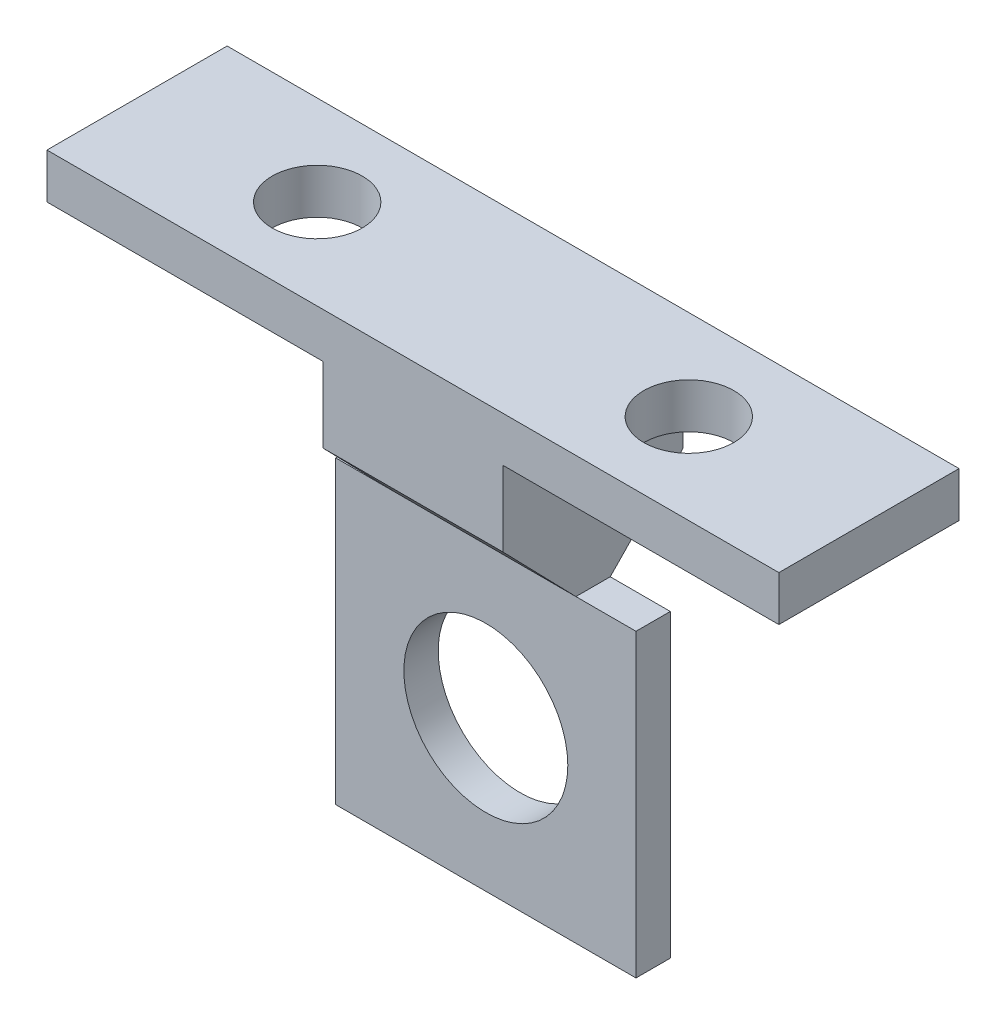
from build123d import *

# Parameters (mm, degrees)
SALIENTE_EXTRUIR1_DEPTH = 2.286
CROQUIS3_W              = 12
CROQUIS3_H              = 3
SALIENTE_EXTRUIR2_DEPTH = 48.748737
SALIENTE_EXTRUIR3_DEPTH = 12
CROQUIS5_R              = 5.46
CORTAR_EXTRUIR1_DEPTH   = 8.143
CROQUIS6_R              = 3
CORTAR_EXTRUIR2_DEPTH   = 3


with BuildPart() as part:
    # Croquis1 → Saliente-Extruir1 (new body)
    with BuildSketch(Plane.XY):
        Polygon((-14.666527812, 16.476832902), (-63.415265152, 16.476832902), (-63.415265152, 13.476832902), (-45.040896482, 13.476832902), (-45.040896482, 8.476832902), (-45.040896482, 3.476832902), (-49.040896482, 3.476832902), (-49.040896482, -16.523167098), (-29.040896482, -16.523167098), (-29.040896482, 3.476832902), (-33.040896482, 3.476832902), (-33.040896482, 8.476832902), (-33.040896482, 13.476832902), (-14.666527812, 13.476832902), align=None)
    extrude(amount=SALIENTE_EXTRUIR1_DEPTH)

    # Croquis3 → Saliente-Extruir2 (add)
    with BuildSketch(Plane.ZY.offset(63.415265152)):
        with Locations((1.143, 14.976832902)):
            Rectangle(CROQUIS3_W, CROQUIS3_H)
    extrude(amount=-SALIENTE_EXTRUIR2_DEPTH)

    # Croquis4 → Saliente-Extruir3 (add)
    with BuildSketch(Plane(origin=(-33.040896482, 0, 0), x_dir=(0, 0, -1), z_dir=(1, 0, 0))):
        Polygon((4.857, 8.476832902), (0, 3.476832902), (-2.286, 3.476832902), (-7.143, 8.476832902), (-7.143, 13.476832902), (4.857, 13.476832902), align=None)
    extrude(amount=-SALIENTE_EXTRUIR3_DEPTH)

    # Croquis5 → Cortar-Extruir1 (cut, through all)
    with BuildSketch(Plane.XY.offset(2.286)):
        with Locations((-39.040896482, -6.523167098)):
            Circle(CROQUIS5_R)
    extrude(amount=-CORTAR_EXTRUIR1_DEPTH, mode=Mode.SUBTRACT)

    # Croquis6 → Cortar-Extruir2 (cut)
    with BuildSketch(Plane(origin=(0, 16.476832902, 0), x_dir=(1, 0, 0), z_dir=(0, 1, 0))):
        with Locations((-26.666529352, -1.143)):
            Circle(CROQUIS6_R)
        with Locations((-51.415263612, -1.143)):
            Circle(CROQUIS6_R)
    extrude(amount=-CORTAR_EXTRUIR2_DEPTH, mode=Mode.SUBTRACT)


solid = part.part
